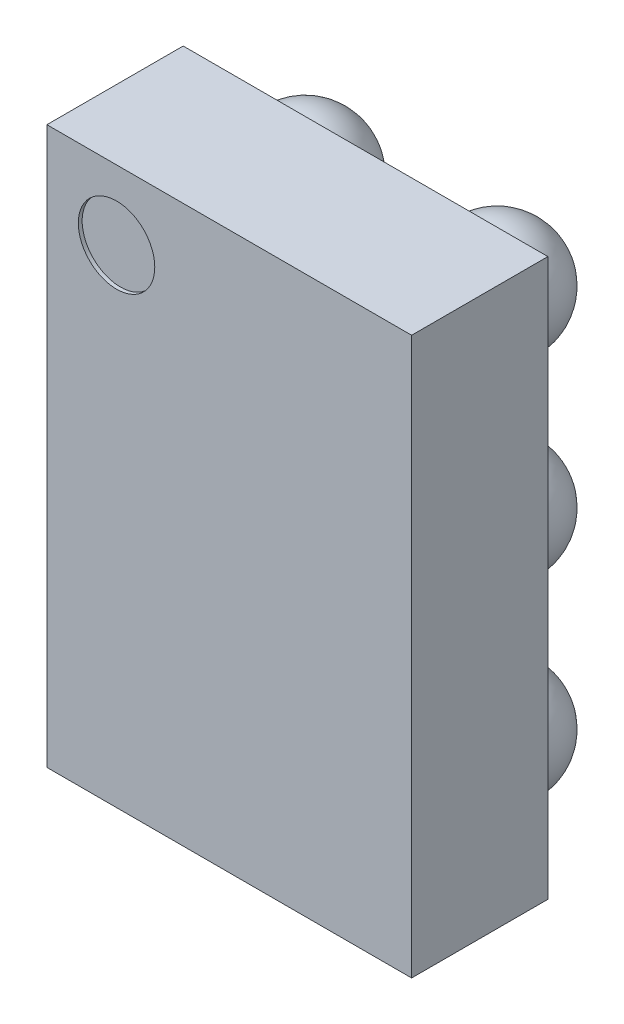
from build123d import *

# Parameters (mm, degrees)
BOSS_EXTRUDE1_START  = 0.24
SKETCH1_W            = 0.95
SKETCH1_H            = 1.45
BOSS_EXTRUDE1_DEPTH  = 0.355
LPATTERN1_COUNT      = 2
LPATTERN1_PITCH      = 0.5
LPATTERN1_COUNT_DIR2 = 3
LPATTERN1_PITCH_DIR2 = 0.5
SKETCH3_R            = 0.0995871
CUT_EXTRUDE1_DEPTH   = 0.01


with BuildPart() as part:
    # Sketch1 → Boss-Extrude1 (new body)
    with BuildSketch(Plane.XY.offset(BOSS_EXTRUDE1_START)):
        Rectangle(SKETCH1_W, SKETCH1_H)
    extrude(amount=BOSS_EXTRUDE1_DEPTH)

    # Sketch2 → Revolve1 (revolve)
    with BuildSketch(Plane(origin=(0.25, 0, 0), x_dir=(0, 0, -1), z_dir=(1, 0, 0))):
        with BuildLine():
            Line((-0.295, 0.5), (0, 0.5))
            ThreePointArc((0, 0.5), (-0.1475, 0.3525), (-0.295, 0.5))
        make_face()
    revolve1 = revolve(axis=Axis((0.25, 0.5, 0.295), (0, 0, -1)))

    # LPattern1: Revolve1 2 × 3
    with Locations(*[(-i * LPATTERN1_PITCH, -j * LPATTERN1_PITCH_DIR2, 0) for i in range(LPATTERN1_COUNT) for j in range(LPATTERN1_COUNT_DIR2) if (i, j) != (0, 0)]):
        add(revolve1)

    # Sketch3 → Cut-Extrude1 (cut)
    with BuildSketch(Plane.XY.offset(0.595)):
        with Locations((-0.293622617, 0.544065437)):
            Circle(SKETCH3_R)
    extrude(amount=-CUT_EXTRUDE1_DEPTH, mode=Mode.SUBTRACT)


solid = part.part
